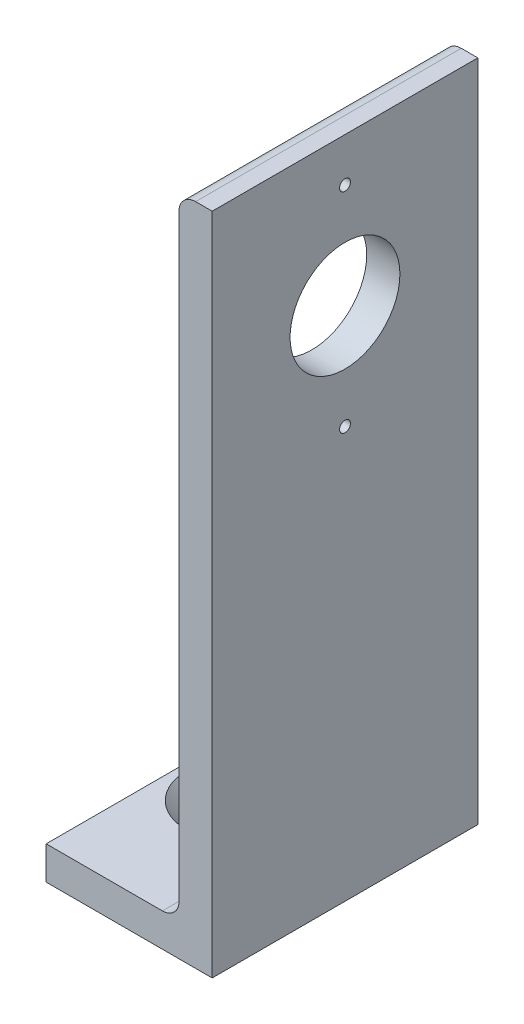
from build123d import *

# Parameters (mm, degrees)
BOSS_EXTRUDE1_DEPTH = 25.4
SKETCH3_R           = 4.765
CUT_EXTRUDE1_DEPTH  = 128
SKETCH4_R           = 10.5
CUT_EXTRUDE2_DEPTH  = 12.7
SKETCH5_R           = 1.04
CUT_EXTRUDE3_DEPTH  = 10


with BuildPart() as part:
    # Sketch2 → Boss-Extrude1 (new body, symmetric)
    with BuildSketch(Plane.XY):
        with BuildLine():
            Line((-15.875, 0), (15.875, 0))
            Line((15.875, 0), (15.875, 127))
            Line((15.875, 127), (12.7, 127))
            ThreePointArc((12.7, 127), (10.45493597, 126.07006403), (9.525, 123.825))
            Line((9.525, 123.825), (9.525, 9.525))
            ThreePointArc((9.525, 9.525), (8.59506403, 7.27993597), (6.35, 6.35))
            Line((6.35, 6.35), (-15.875, 6.35))
            Line((-15.875, 6.35), (-15.875, 0))
        make_face()
    extrude(amount=BOSS_EXTRUDE1_DEPTH, both=True)

    # Sketch3 → Cut-Extrude1 (cut, through all)
    with BuildSketch(Plane.XZ):
        with Locations((-4.826, 0)):
            Circle(SKETCH3_R)
    extrude(amount=-CUT_EXTRUDE1_DEPTH, mode=Mode.SUBTRACT)

    # Sketch4 → Cut-Extrude2 (cut)
    with BuildSketch(Plane(origin=(15.875, 0, 0), x_dir=(0, 0, -1), z_dir=(1, 0, 0))):
        with Locations((0, 98.65)):
            Circle(SKETCH4_R)
    extrude(amount=-CUT_EXTRUDE2_DEPTH, mode=Mode.SUBTRACT)

    # Sketch5 → Cut-Extrude3 (cut)
    with BuildSketch(Plane(origin=(15.875, 0, 0), x_dir=(0, 0, -1), z_dir=(1, 0, 0))):
        with Locations((0, 78.65)):
            Circle(SKETCH5_R)
        with Locations((0, 118.65)):
            Circle(SKETCH5_R)
    extrude(amount=-CUT_EXTRUDE3_DEPTH, mode=Mode.SUBTRACT)

    # Sketch7 → CSK for 3/8 Flat Head Machine Screw1 (revolve, cut)
    with BuildSketch(Plane(origin=(-4.826, 6.35, 0), x_dir=(0, 0, 1), z_dir=(1, 0, 0))):
        Polygon((0, 0), (0, 6.35), (5.15874, 6.35), (5.15874, 5.198123707), (9.6774, 0), align=None)
    revolve(axis=Axis((-4.826, 12.7, 0), (0, -1, 0)), mode=Mode.SUBTRACT)


solid = part.part
